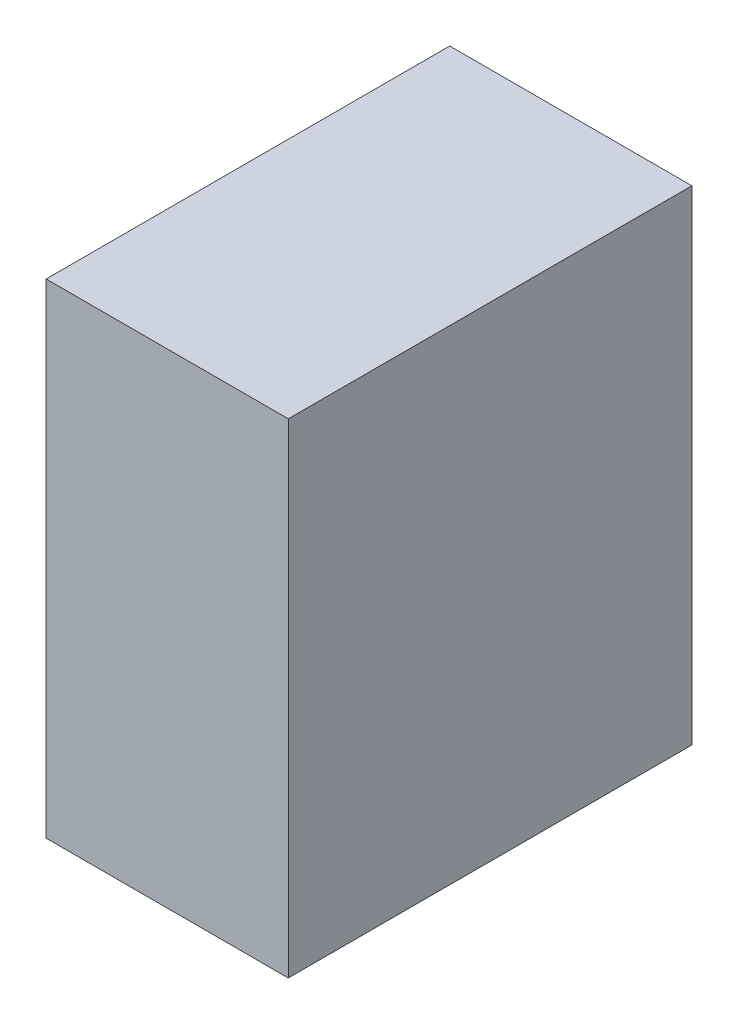
from build123d import *

# Parameters (mm, degrees)
SKETCH1_W           = 76.2
SKETCH1_H           = 127
BOSS_EXTRUDE1_DEPTH = 152.4


with BuildPart() as part:
    # Sketch1 → Boss-Extrude1 (new body)
    with BuildSketch(Plane(origin=(0, 0, 0), x_dir=(1, 0, 0), z_dir=(0, 1, 0))):
        Rectangle(SKETCH1_W, SKETCH1_H)
    extrude(amount=BOSS_EXTRUDE1_DEPTH)


solid = part.part
